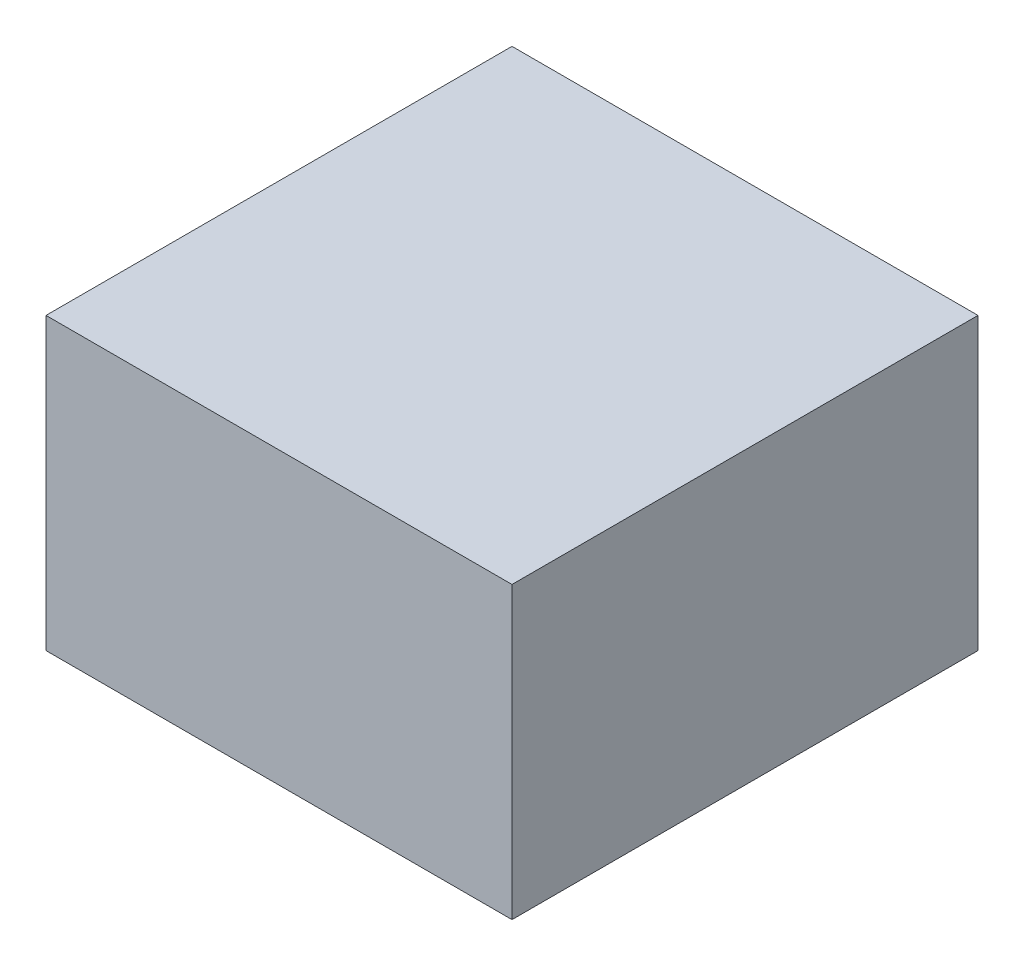
from build123d import *

# Parameters (mm, degrees)
SKETCH1_W           = 154.94
SKETCH1_H           = 154.94
BOSS_EXTRUDE1_DEPTH = 96.52


with BuildPart() as part:
    # Sketch1 → Boss-Extrude1 (new body)
    with BuildSketch(Plane(origin=(0, 0, 0), x_dir=(1, 0, 0), z_dir=(0, 1, 0))):
        with Locations((77.47, -77.47)):
            Rectangle(SKETCH1_W, SKETCH1_H)
    extrude(amount=BOSS_EXTRUDE1_DEPTH)


solid = part.part
